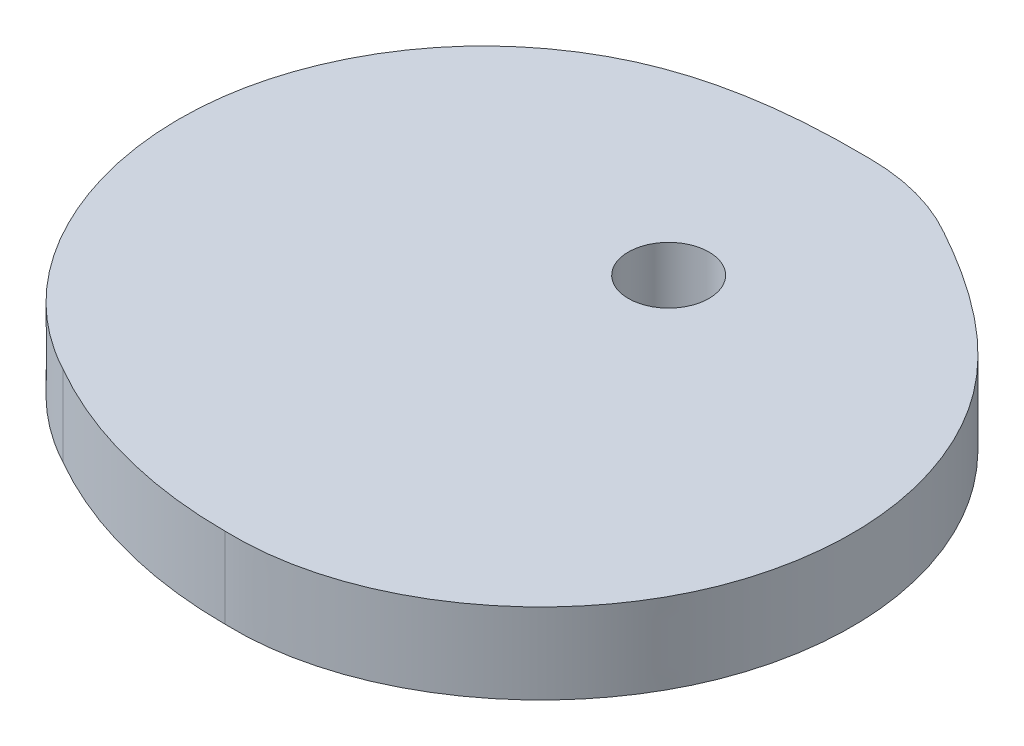
from build123d import *

# Parameters (mm, degrees)
SKETCH2_R           = 5
BOSS_EXTRUDE1_DEPTH = 10


with BuildPart() as part:
    # Sketch2 → Boss-Extrude1 (new body)
    with BuildSketch(Plane(origin=(0, 0, 0), x_dir=(1, 0, 0), z_dir=(0, 1, 0))):
        with BuildLine():
            ThreePointArc((-27.5, -47.631397208), (-14.235047481, -53.125920446), (0, -55))
            add(Edge.make_bspline(
                [(0, -55), (15.821995191, -55.521684642), (37.158196695, -40.15721482), (40.409843735, -11.080588617), (32.003444862, 9.061174356), (19.786389501, 17.600648721), (12.5, 21.650635095)],
                knots=[0, 0, 0, 0, 0.421298926, 0.607822378, 0.766892621, 1, 1, 1, 1], degree=3))
            ThreePointArc((12.5, 21.650635095), (6.470476128, 24.148145657), (0, 25))
            add(Edge.make_bspline(
                [(0, 25), (-8.335191597, 25.135803666), (-23.185209081, 23.848929612), (-40.536245546, 10.608850636), (-52.258549707, -16.198069832), (-41.463092095, -40.172191766), (-27.5, -47.631397208)],
                knots=[0, 0, 0, 0, 0.233107379, 0.392177622, 0.578701074, 1, 1, 1, 1], degree=3))
        make_face()
        Circle(SKETCH2_R, mode=Mode.SUBTRACT)
    extrude(amount=BOSS_EXTRUDE1_DEPTH)


solid = part.part
